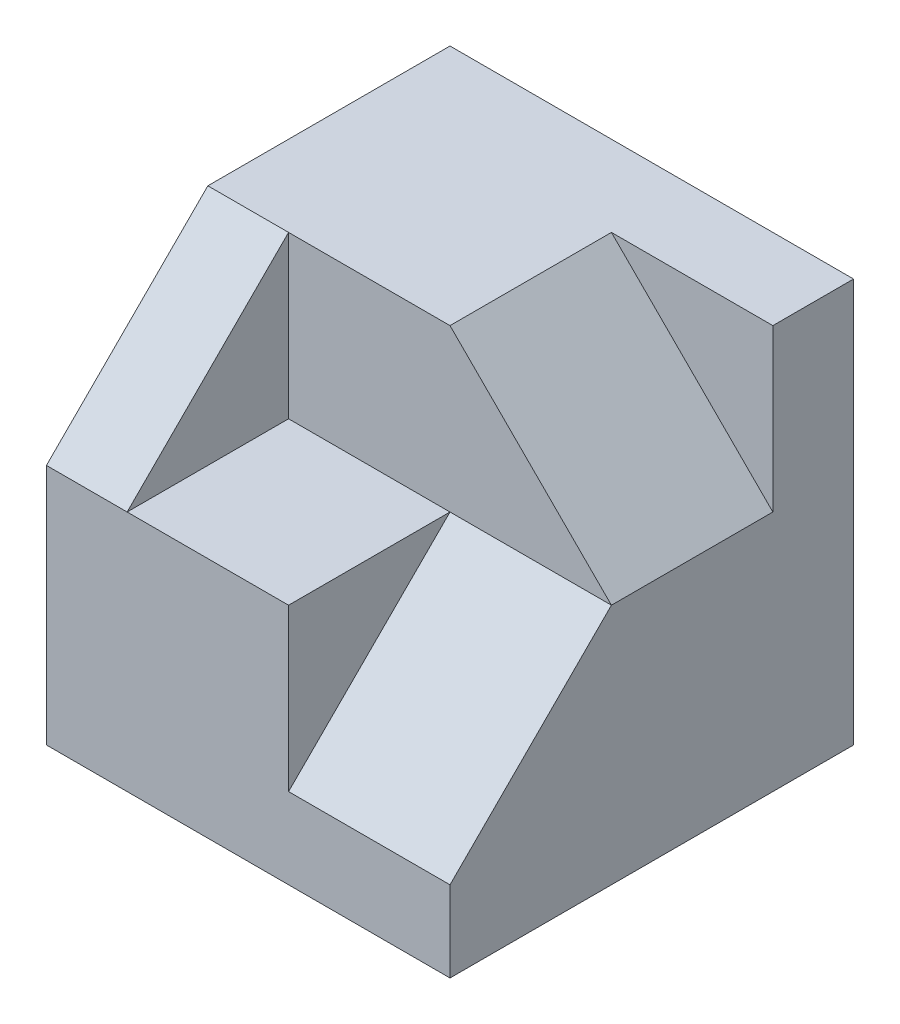
from build123d import *

# Parameters (mm, degrees)
SKETCH1_W           = 5
SKETCH1_H           = 5
BOSS_EXTRUDE1_DEPTH = 5
CUT_EXTRUDE1_DEPTH  = 4
SKETCH3_W           = 4
SKETCH3_H           = 2
CUT_EXTRUDE3_DEPTH  = 2
CUT_EXTRUDE4_DEPTH  = 2
CUT_EXTRUDE5_DEPTH  = 2
CUT_EXTRUDE6_DEPTH  = 2


with BuildPart() as part:
    # Sketch1 → Boss-Extrude1 (new body)
    with BuildSketch(Plane.XY):
        Rectangle(SKETCH1_W, SKETCH1_H)
    extrude(amount=BOSS_EXTRUDE1_DEPTH)

    # Sketch2 → Cut-Extrude1 (cut)
    with BuildSketch(Plane(origin=(2.5, 0, 0), x_dir=(0, 0, -1), z_dir=(1, 0, 0))):
        Polygon((-3, 2.5), (-5, 0.5), (-5, 2.5), align=None)
    extrude(amount=-CUT_EXTRUDE1_DEPTH, mode=Mode.SUBTRACT)

    # Sketch3 → Cut-Extrude3 (cut)
    with BuildSketch(Plane(origin=(0, 2.5, 0), x_dir=(1, 0, 0), z_dir=(0, 1, 0))):
        with Locations((0.5, -4)):
            Rectangle(SKETCH3_W, SKETCH3_H)
    extrude(amount=-CUT_EXTRUDE3_DEPTH, mode=Mode.SUBTRACT)

    # Sketch4 → Cut-Extrude4 (cut)
    with BuildSketch(Plane(origin=(2.5, 0, 0), x_dir=(0, 0, -1), z_dir=(1, 0, 0))):
        Polygon((-3, 0.5), (-5, -1.5), (-5, 0.5), align=None)
    extrude(amount=-CUT_EXTRUDE4_DEPTH, mode=Mode.SUBTRACT)

    # Sketch5 → Cut-Extrude5 (cut)
    with BuildSketch(Plane.XY.offset(3)):
        Polygon((0.5, 2.5), (2.5, 0.5), (2.5, 2.5), align=None)
    extrude(amount=-CUT_EXTRUDE5_DEPTH, mode=Mode.SUBTRACT)

    # Sketch6 → Cut-Extrude6 (cut, through all)
    with BuildSketch(Plane(origin=(-1.5, 0, 0), x_dir=(0, 0, -1), z_dir=(1, 0, 0))):
        Polygon((-3, 2.5), (-5, 0.5), (-5, 2.5), align=None)
    extrude(amount=-CUT_EXTRUDE6_DEPTH, mode=Mode.SUBTRACT)


solid = part.part
